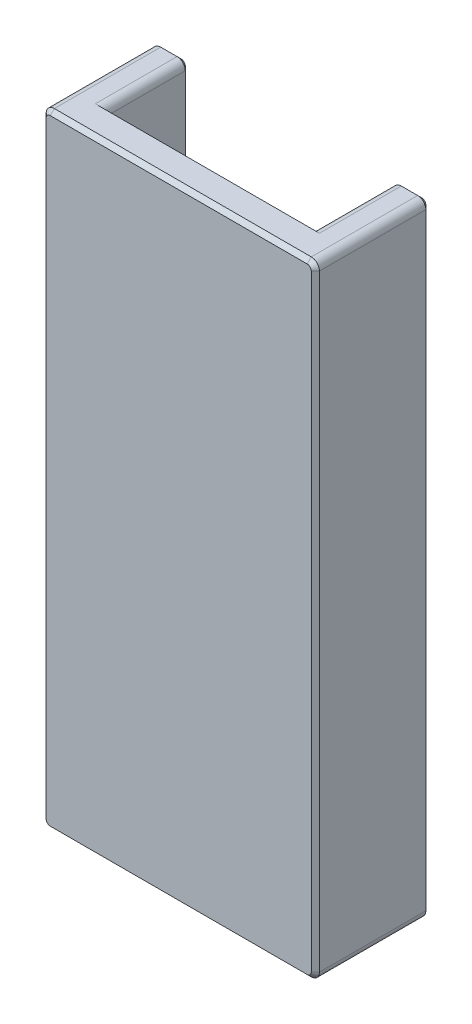
from build123d import *

# Parameters (mm, degrees)
SKETCH1_W           = 33.4
SKETCH1_H           = 76.2
BOSS_EXTRUDE1_DEPTH = 4
SKETCH1_3_W         = 4
SKETCH1_3_H         = 76.2
BOSS_EXTRUDE2_DEPTH = 10
FILLET1_R           = 1
CHAMFER1_SIZE       = 0.5


with BuildPart() as part:
    # Sketch1 → Boss-Extrude1 (new body)
    with BuildSketch(Plane.XY):
        with Locations((0, 12.7)):
            Rectangle(SKETCH1_W, SKETCH1_H)
    extrude(amount=BOSS_EXTRUDE1_DEPTH)

    # Sketch1_3 → Boss-Extrude2 (add)
    with BuildSketch(Plane.XY):
        with Locations((-14.7, 12.7)):
            Rectangle(SKETCH1_3_W, SKETCH1_3_H)
        with Locations((14.7, 12.7)):
            Rectangle(SKETCH1_3_W, SKETCH1_3_H)
    extrude(amount=-BOSS_EXTRUDE2_DEPTH)

    # Fillet1
    fillet1_edges = [part.edges().sort_by_distance(p)[0] for p in [
        (12.7, 50.8, -5),
        (-12.7, 50.8, -5),
        (-12.7, -25.4, -5),
        (12.7, -25.4, -5),
        (-16.7, -25.4, -3),
        (16.7, -25.4, -3),
        (16.7, 50.8, -3),
        (-16.7, 50.8, -3),
    ]]
    fillet(fillet1_edges, radius=FILLET1_R)

    # Chamfer1
    chamfer1_edges = [part.edges().sort_by_distance(p)[0] for p in [
        (-16.407106781, 50.507106781, 4),
        (0, 50.8, 4),
        (16.407106781, 50.507106781, 4),
        (16.7, 12.7, 4),
        (16.407106781, -25.107106781, 4),
        (0, -25.4, 4),
        (-16.407106781, -25.107106781, 4),
        (-16.7, 12.7, 4),
        (-16.407106781, 50.507106781, -10),
        (-16.7, 12.7, -10),
        (-16.407106781, -25.107106781, -10),
        (-14.7, -25.4, -10),
        (-12.992893219, -25.107106781, -10),
        (-12.7, 12.7, -10),
        (-12.992893219, 50.507106781, -10),
        (-14.7, 50.8, -10),
        (12.992893219, -25.107106781, -10),
        (14.7, -25.4, -10),
        (16.407106781, -25.107106781, -10),
        (16.7, 12.7, -10),
        (16.407106781, 50.507106781, -10),
        (14.7, 50.8, -10),
        (12.992893219, 50.507106781, -10),
        (12.7, 12.7, -10),
        (0, 50.8, 0),
        (0, -25.4, 0),
    ]]
    chamfer(chamfer1_edges, length=CHAMFER1_SIZE)


solid = part.part
